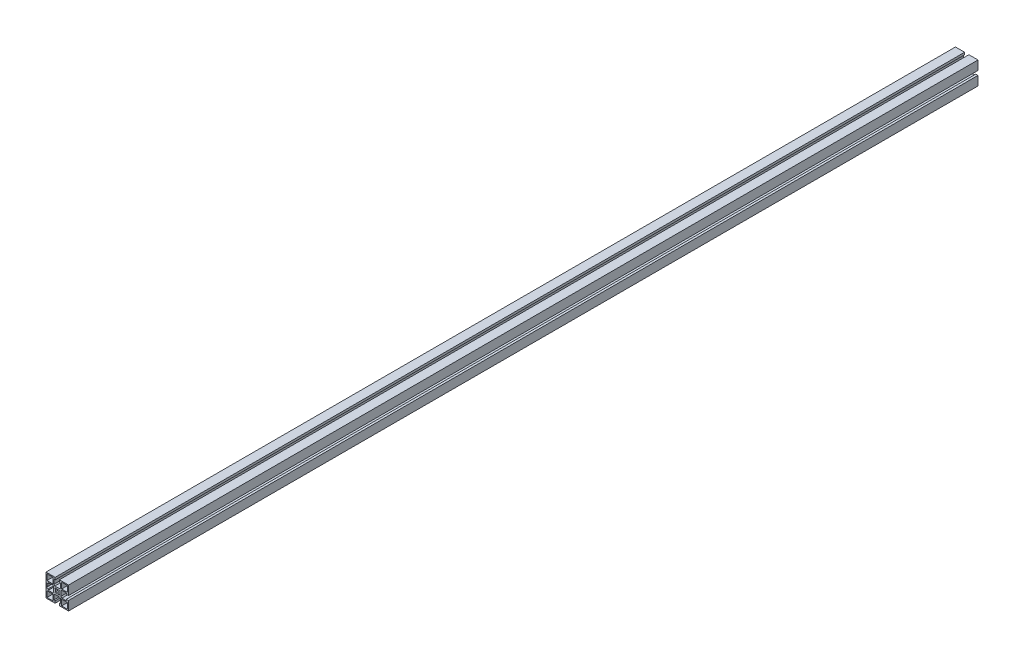
from build123d import *

# Parameters (mm, degrees)
SKETCH1_W           = 11.699975178
SKETCH1_H           = 11.699996949
SKETCH1_W_2         = 11.699990436
SKETCH1_H_2         = 11.699981689
SKETCH1_W_3         = 11.699990437
SKETCH1_H_3         = 11.699975177
SKETCH1_W_4         = 11.699981689
SKETCH1_H_4         = 11.699990436
BOSS_EXTRUDE1_DEPTH = 1817.878
CUT_EXTRUDE1_REACH  = 1820.156


with BuildPart() as part:
    # Sketch1 → Boss-Extrude1 (new body)
    with BuildSketch(Plane.XY):
        Polygon((22.500515052, 22.499297556), (-22.499484399, 22.499298105), (-22.499484948, -22.500701346), (-4.249491942, -22.500701568), (-4.249491942, -22.200733242), (-4.24949208, -18.000719999), (-6.799479919, -18.000719999), (-6.799480207, -9.200732353), (-4.799480391, -7.200732362), (4.800525817, -7.200732047), (6.8005258, -9.200731855), (6.800526088, -18.000720263), (4.250507877, -18.000720263), (4.250508015, -22.200733153), (4.250508015, -22.500701672), (22.500514502, -22.500701895), (22.500514725, -4.250714302), (22.200520351, -4.250714302), (18.000507108, -4.25071444), (18.000507108, -6.800702279), (9.200519462, -6.800702567), (7.200519471, -4.800702751), (7.200519156, 4.799303458), (9.200518964, 6.79930344), (18.000507424, 6.799303729), (18.000507424, 4.249285514), (22.200520261, 4.249285652), (22.500514829, 4.249285652), align=None)
        with BuildLine():
            Line((-4.249491247, 17.999291576), (-4.249490956, 22.199304807))
            Line((-4.249490956, 22.199304807), (-3.949472548, 22.199304807))
            Line((-3.949472548, 22.199304807), (-3.481695222, 21.73152644))
            ThreePointArc((-3.481695222, 21.73152644), (-2.670636178, 21.189593132), (-1.713926324, 20.999291428))
            Line((-1.713926324, 20.999291428), (1.714975167, 20.999291428))
            ThreePointArc((1.714975167, 20.999291428), (2.671722509, 21.189608628), (3.482801459, 21.731583767))
            Line((3.482801459, 21.731583767), (3.950490798, 22.199304487))
            Line((3.950490798, 22.199304487), (4.250509108, 22.199304487))
            Line((4.250509108, 22.199304487), (4.250508817, 17.999291575))
            Line((4.250508817, 17.999291575), (6.800527063, 17.999291575))
            Line((6.800527063, 17.999291575), (6.800526453, 9.199302988))
            Line((6.800526453, 9.199302988), (4.800526064, 7.199302969))
            Line((4.800526064, 7.199302969), (-4.799479817, 7.199303635))
            Line((-4.799479817, 7.199303635), (-6.799479854, 9.199304042))
            Line((-6.799479854, 9.199304042), (-6.799479244, 17.999291576))
            Line((-6.799479244, 17.999291576), (-4.249491247, 17.999291576))
        make_face(mode=Mode.SUBTRACT)
        with BuildLine():
            Line((-17.99949762, -4.250714253), (-22.199510799, -4.250714391))
            Line((-22.199510799, -4.250714391), (-22.199510799, -3.950696126))
            Line((-22.199510799, -3.950696126), (-21.731790056, -3.48300681))
            ThreePointArc((-21.731790056, -3.48300681), (-21.189814855, -2.671927844), (-20.999497617, -1.71518046))
            Line((-20.999497617, -1.71518046), (-20.999497617, 1.713721031))
            ThreePointArc((-20.999497617, 1.713721031), (-21.189799286, 2.670430863), (-21.731732544, 3.481489907))
            Line((-21.731732544, 3.481489907), (-22.199510888, 3.949267256))
            Line((-22.199510888, 3.949267256), (-22.199510888, 4.249285566))
            Line((-22.199510888, 4.249285566), (-17.999497356, 4.249285704))
            Line((-17.999497356, 4.249285704), (-17.999497356, 6.79927354))
            Line((-17.999497356, 6.79927354), (-9.199509947, 6.799273828))
            Line((-9.199509947, 6.799273828), (-7.199509956, 4.799274012))
            Line((-7.199509956, 4.799274012), (-7.199509641, -4.800732197))
            Line((-7.199509641, -4.800732197), (-9.199509449, -6.800732179))
            Line((-9.199509449, -6.800732179), (-17.99949762, -6.800732468))
            Line((-17.99949762, -6.800732468), (-17.99949762, -4.250714253))
        make_face(mode=Mode.SUBTRACT)
        with Locations((-14.649542346, -14.650709384)):
            Rectangle(SKETCH1_W, SKETCH1_H, mode=Mode.SUBTRACT)
        with Locations((14.65050626, -14.650767962)):
            Rectangle(SKETCH1_W_2, SKETCH1_H_2, mode=Mode.SUBTRACT)
        with BuildLine():
            Line((-3.181457266, -4.596908447), (-4.595670829, -3.182694885))
            Line((-4.595670829, -3.182694885), (-3.26221457, -1.849238626))
            ThreePointArc((-3.26221457, -1.849238626), (-3.749476751, -0.00071437), (-3.26221457, 1.847809887))
            Line((-3.26221457, 1.847809887), (-4.595670829, 3.181266146))
            Line((-4.595670829, 3.181266146), (-3.181457266, 4.595479708))
            Line((-3.181457266, 4.595479708), (-1.848001007, 3.262023449))
            ThreePointArc((-1.848001007, 3.262023449), (0.000523249, 3.74928563), (1.849047505, 3.262023449))
            Line((1.849047505, 3.262023449), (3.182503764, 4.595479708))
            Line((3.182503764, 4.595479708), (4.596717327, 3.181266146))
            Line((4.596717327, 3.181266146), (3.263261068, 1.847809887))
            ThreePointArc((3.263261068, 1.847809887), (3.750523249, -0.00071437), (3.263261068, -1.849238626))
            Line((3.263261068, -1.849238626), (4.596717327, -3.182694885))
            Line((4.596717327, -3.182694885), (3.182503764, -4.596908447))
            Line((3.182503764, -4.596908447), (1.849047505, -3.263452188))
            ThreePointArc((1.849047505, -3.263452188), (0.000523249, -3.75071437), (-1.848001007, -3.263452188))
            Line((-1.848001007, -3.263452188), (-3.181457266, -4.596908447))
        make_face(mode=Mode.SUBTRACT)
        with Locations((-14.64949028, 14.649335967)):
            Rectangle(SKETCH1_W_3, SKETCH1_H_3, mode=Mode.SUBTRACT)
        with Locations((14.650561583, 14.6492839)):
            Rectangle(SKETCH1_W_4, SKETCH1_H_4, mode=Mode.SUBTRACT)
    extrude(amount=BOSS_EXTRUDE1_DEPTH)

    # Sketch1_4 → Cut-Extrude1 (cut, up to next)
    with BuildSketch(Plane.XY, mode=Mode.PRIVATE) as cut_extrude1_sk1:
        with BuildLine():
            Line((-4.249490956, 22.499297883), (-4.249490956, 22.199304807))
            Line((-4.249490956, 22.199304807), (-3.949472548, 22.199304807))
            Line((-3.949472548, 22.199304807), (-3.481695222, 21.73152644))
            ThreePointArc((-3.481695222, 21.73152644), (-2.670636178, 21.189593132), (-1.713926324, 20.999291428))
            Line((-1.713926324, 20.999291428), (1.714975167, 20.999291428))
            ThreePointArc((1.714975167, 20.999291428), (2.671722509, 21.189608628), (3.482801459, 21.731583767))
            Line((3.482801459, 21.731583767), (3.950490798, 22.199304487))
            Line((3.950490798, 22.199304487), (4.250509108, 22.199304487))
            Line((4.250509108, 22.199304487), (4.250509108, 22.499297779))
            Line((4.250509108, 22.499297779), (-4.249490956, 22.499297883))
        make_face()
    cut_extrude1_tool1 = extrude(cut_extrude1_sk1.sketch, amount=CUT_EXTRUDE1_REACH, mode=Mode.PRIVATE) & part.part
    add(cut_extrude1_tool1.solids().sort_by_distance((0.000518, 21.824215, 0))[0], mode=Mode.SUBTRACT)


solid = part.part
